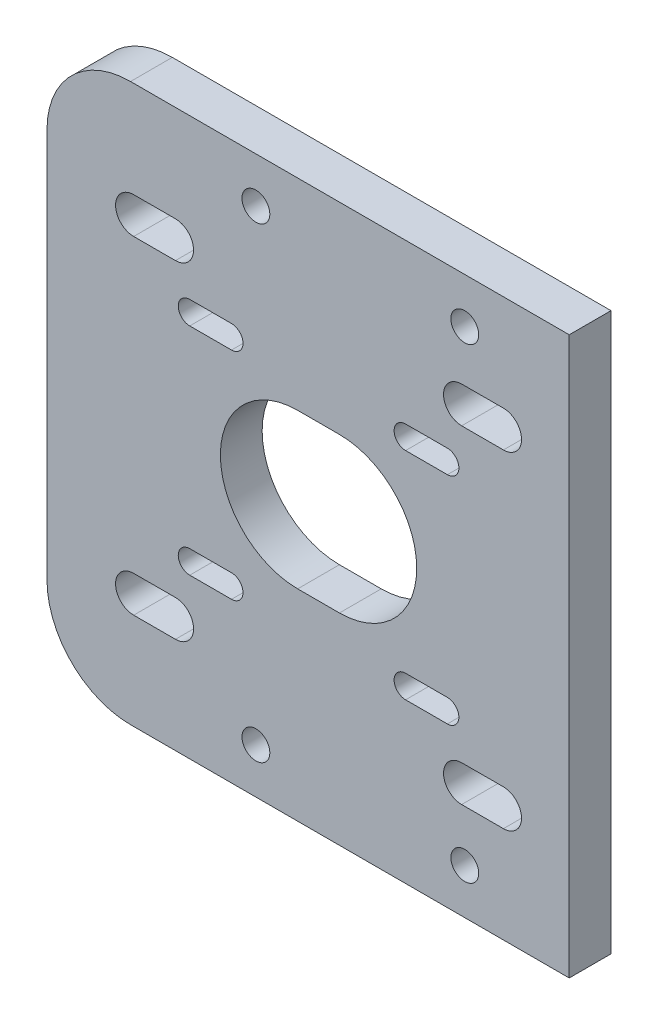
from build123d import *

# Parameters (mm, degrees)
CROQUIS1_W              = 75
CROQUIS1_H              = 80
SALIENTE_EXTRUIR1_DEPTH = 6
CORTAR_EXTRUIR1_DEPTH   = 7
REDONDEO1_R             = 12
CROQUIS3_R              = 2
CORTAR_EXTRUIR2_DEPTH   = 7


with BuildPart() as part:
    # Croquis1 → Saliente-Extruir1 (new body)
    with BuildSketch(Plane.XY):
        with Locations((37.5, 40)):
            Rectangle(CROQUIS1_W, CROQUIS1_H)
    extrude(amount=SALIENTE_EXTRUIR1_DEPTH)

    # Croquis2 → Cortar-Extruir1 (cut, through all)
    with BuildSketch(Plane(origin=(0, 0, 0), x_dir=(-1, 0, 0), z_dir=(0, 0, -1))):
        with BuildLine():
            Line((-36, 28.9), (-42, 28.9))
            ThreePointArc((-42, 28.9), (-53.1, 40), (-42, 51.1))
            Line((-42, 51.1), (-36, 51.1))
            ThreePointArc((-36, 51.1), (-24.9, 40), (-36, 28.9))
        make_face()
        with BuildLine():
            Line((-20.5, 22.85), (-26.5, 22.85))
            ThreePointArc((-26.5, 22.85), (-28.15, 24.5), (-26.5, 26.15))
            Line((-26.5, 26.15), (-20.5, 26.15))
            ThreePointArc((-20.5, 26.15), (-18.85, 24.5), (-20.5, 22.85))
        make_face()
        with BuildLine():
            Line((-51.5, 53.85), (-57.5, 53.85))
            ThreePointArc((-57.5, 53.85), (-59.15, 55.5), (-57.5, 57.15))
            Line((-57.5, 57.15), (-51.5, 57.15))
            ThreePointArc((-51.5, 57.15), (-49.85, 55.5), (-51.5, 53.85))
        make_face()
        with BuildLine():
            Line((-51.5, 22.85), (-57.5, 22.85))
            ThreePointArc((-57.5, 22.85), (-59.15, 24.5), (-57.5, 26.15))
            Line((-57.5, 26.15), (-51.5, 26.15))
            ThreePointArc((-51.5, 26.15), (-49.85, 24.5), (-51.5, 22.85))
        make_face()
        with BuildLine():
            Line((-20.5, 53.85), (-26.5, 53.85))
            ThreePointArc((-26.5, 53.85), (-28.15, 55.5), (-26.5, 57.15))
            Line((-26.5, 57.15), (-20.5, 57.15))
            ThreePointArc((-20.5, 57.15), (-18.85, 55.5), (-20.5, 53.85))
        make_face()
        with BuildLine():
            Line((-12.45, 13.85), (-18.45, 13.85))
            ThreePointArc((-18.45, 13.85), (-21.05, 16.45), (-18.45, 19.05))
            Line((-18.45, 19.05), (-12.45, 19.05))
            ThreePointArc((-12.45, 19.05), (-9.85, 16.45), (-12.45, 13.85))
        make_face()
        with BuildLine():
            Line((-59.55, 13.85), (-65.55, 13.85))
            ThreePointArc((-65.55, 13.85), (-68.15, 16.45), (-65.55, 19.05))
            Line((-65.55, 19.05), (-59.55, 19.05))
            ThreePointArc((-59.55, 19.05), (-56.95, 16.45), (-59.55, 13.85))
        make_face()
        with BuildLine():
            Line((-12.45, 60.95), (-18.45, 60.95))
            ThreePointArc((-18.45, 60.95), (-21.05, 63.55), (-18.45, 66.15))
            Line((-18.45, 66.15), (-12.45, 66.15))
            ThreePointArc((-12.45, 66.15), (-9.85, 63.55), (-12.45, 60.95))
        make_face()
        with BuildLine():
            Line((-59.55, 60.95), (-65.55, 60.95))
            ThreePointArc((-65.55, 60.95), (-68.15, 63.55), (-65.55, 66.15))
            Line((-65.55, 66.15), (-59.55, 66.15))
            ThreePointArc((-59.55, 66.15), (-56.95, 63.55), (-59.55, 60.95))
        make_face()
    extrude(amount=-CORTAR_EXTRUIR1_DEPTH, mode=Mode.SUBTRACT)

    # Redondeo1
    redondeo1_edges = [part.edges().sort_by_distance(p)[0] for p in [
        (0, 80, 3),
        (0, 0, 3),
    ]]
    fillet(redondeo1_edges, radius=REDONDEO1_R)

    # Croquis3 → Cortar-Extruir2 (cut, through all)
    with BuildSketch(Plane(origin=(0, 0, 0), x_dir=(-1, 0, 0), z_dir=(0, 0, -1))):
        with Locations((-60, 6.5)):
            Circle(CROQUIS3_R)
        with Locations((-30, 6.5)):
            Circle(CROQUIS3_R)
        with Locations((-60, 73.5)):
            Circle(CROQUIS3_R)
        with Locations((-30, 73.5)):
            Circle(CROQUIS3_R)
    extrude(amount=-CORTAR_EXTRUIR2_DEPTH, mode=Mode.SUBTRACT)


solid = part.part
